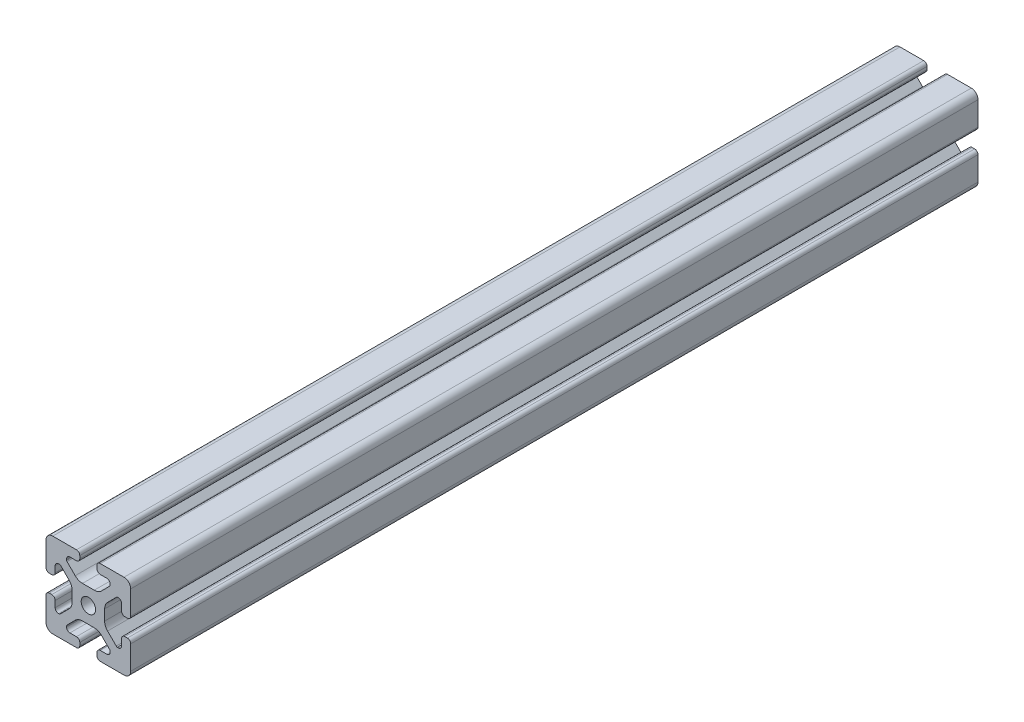
from build123d import *

# Parameters (mm, degrees)
SKETCH1_R           = 3.4
BOSS_EXTRUDE1_DEPTH = 400


with BuildPart() as part:
    # Sketch1 → Boss-Extrude1 (new body)
    with BuildSketch(Plane.XY):
        with BuildLine():
            Line((-8.715, -15.524615034), (-5.63, -15.524615034))
            ThreePointArc((-5.63, -15.524615034), (-4.519842354, -15.984457388), (-4.06, -17.094615034))
            Line((-4.06, -17.094615034), (-4.06, -18.43))
            ThreePointArc((-4.06, -18.43), (-4.519842354, -19.540157646), (-5.63, -20))
            Line((-5.63, -20), (-16.674615034, -20))
            ThreePointArc((-16.674615034, -20), (-18.951578385, -19.194274381), (-20, -17.018368134))
            Line((-20, -17.018368134), (-20, -5.757918808))
            ThreePointArc((-20, -5.757918808), (-19.564709668, -4.603883664), (-18.43, -4.120449326))
            Line((-18.43, -4.120449326), (-17.248545805, -4.120449326))
            ThreePointArc((-17.248545805, -4.120449326), (-16.114784845, -4.604407881), (-15.67999625, -5.757919334))
            Line((-15.67999625, -5.757919334), (-15.67999625, -8.715399492))
            ThreePointArc((-15.67999625, -8.715399492), (-15.220153896, -9.825557139), (-14.10999625, -10.285399492))
            Line((-14.10999625, -10.285399492), (-13.816903094, -10.285399492))
            ThreePointArc((-13.816903094, -10.285399492), (-13.526063686, -10.227547937), (-13.279501941, -10.062800646))
            Line((-13.279501941, -10.062800646), (-9.076242789, -5.859541495))
            ThreePointArc((-9.076242789, -5.859541495), (-8.046572221, -4.318530588), (-7.685, -2.500784284))
            Line((-7.685, -2.500784284), (-7.685, 2.500784284))
            ThreePointArc((-7.685, 2.500784284), (-8.046572221, 4.318530588), (-9.076242789, 5.859541495))
            Line((-9.076242789, 5.859541495), (-13.040489136, 9.823787841))
            ThreePointArc((-13.040489136, 9.823787841), (-13.354224618, 10.012729352), (-13.71989919, 10.033001362))
            Line((-13.71989919, 10.033001362), (-14.05520779, 10.044710596))
            ThreePointArc((-14.05520779, 10.044710596), (-15.200613642, 9.605030484), (-15.68, 8.475666998))
            Line((-15.68, 8.475666998), (-15.68, 5.572979049))
            ThreePointArc((-15.68, 5.572979049), (-16.139842354, 4.462821403), (-17.25, 4.002979049))
            Line((-17.25, 4.002979049), (-18.43, 4.002979049))
            ThreePointArc((-18.43, 4.002979049), (-19.540157646, 4.462821403), (-20, 5.572979049))
            Line((-20, 5.572979049), (-20, 13.004526564))
            Line((-20, 13.004526564), (-20, 16.83))
            ThreePointArc((-20, 16.83), (-19.071528496, 19.071528496), (-16.83, 20))
            Line((-16.83, 20), (-5.63, 20))
            ThreePointArc((-5.63, 20), (-4.519842354, 19.540157646), (-4.06, 18.43))
            Line((-4.06, 18.43), (-4.06, 17.094615034))
            ThreePointArc((-4.06, 17.094615034), (-4.519842354, 15.984457388), (-5.63, 15.524615034))
            Line((-5.63, 15.524615034), (-8.715, 15.524615034))
            ThreePointArc((-8.715, 15.524615034), (-9.825157646, 15.06477268), (-10.285, 13.954615034))
            Line((-10.285, 13.954615034), (-10.285, 13.492503602))
            ThreePointArc((-10.285, 13.492503602), (-10.227148445, 13.201664194), (-10.062401154, 12.955102448))
            Line((-10.062401154, 12.955102448), (-6.217092793, 9.109794088))
            ThreePointArc((-6.217092793, 9.109794088), (-4.63891877, 8.055291919), (-2.777335583, 7.685))
            Line((-2.777335583, 7.685), (2.777335583, 7.685))
            ThreePointArc((2.777335583, 7.685), (4.63891877, 8.055291919), (6.217092793, 9.109794088))
            Line((6.217092793, 9.109794088), (10.062401154, 12.955102448))
            ThreePointArc((10.062401154, 12.955102448), (10.227148445, 13.201664194), (10.285, 13.492503602))
            Line((10.285, 13.492503602), (10.285, 13.954615034))
            ThreePointArc((10.285, 13.954615034), (9.825157646, 15.06477268), (8.715, 15.524615034))
            Line((8.715, 15.524615034), (5.63, 15.524615034))
            ThreePointArc((5.63, 15.524615034), (4.519842354, 15.984457388), (4.06, 17.094615034))
            Line((4.06, 17.094615034), (4.06, 18.43))
            ThreePointArc((4.06, 18.43), (4.519842354, 19.540157646), (5.63, 20))
            Line((5.63, 20), (12.979635074, 20))
            Line((12.979635074, 20), (16.83, 20))
            ThreePointArc((16.83, 20), (19.071528496, 19.071528496), (20, 16.83))
            Line((20, 16.83), (20, 13.001098436))
            Line((20, 13.001098436), (20, 5.630000526))
            ThreePointArc((20, 5.630000526), (19.540157646, 4.519842879), (18.43, 4.060000526))
            Line((18.43, 4.060000526), (17.24999625, 4.060000526))
            ThreePointArc((17.24999625, 4.060000526), (16.139838603, 4.519842879), (15.67999625, 5.630000526))
            Line((15.67999625, 5.630000526), (15.67999625, 8.715399492))
            ThreePointArc((15.67999625, 8.715399492), (15.220153896, 9.825557139), (14.10999625, 10.285399492))
            Line((14.10999625, 10.285399492), (13.816903094, 10.285399492))
            ThreePointArc((13.816903094, 10.285399492), (13.526063686, 10.227547937), (13.279501941, 10.062800646))
            Line((13.279501941, 10.062800646), (9.076242789, 5.859541495))
            ThreePointArc((9.076242789, 5.859541495), (8.046572221, 4.318530588), (7.685, 2.500784284))
            Line((7.685, 2.500784284), (7.685, -2.500784284))
            ThreePointArc((7.685, -2.500784284), (8.046572221, -4.318530588), (9.076242789, -5.859541495))
            Line((9.076242789, -5.859541495), (13.163657296, -9.946956002))
            ThreePointArc((13.163657296, -9.946956002), (13.35903797, -10.160433474), (13.6200547, -10.285399492))
            Line((13.6200547, -10.285399492), (14.10999625, -10.285399492))
            ThreePointArc((14.10999625, -10.285399492), (15.220153896, -9.825557139), (15.67999625, -8.715399492))
            Line((15.67999625, -8.715399492), (15.67999625, -5.630000526))
            ThreePointArc((15.67999625, -5.630000526), (16.139838603, -4.519842879), (17.24999625, -4.060000526))
            Line((17.24999625, -4.060000526), (18.43, -4.060000526))
            ThreePointArc((18.43, -4.060000526), (19.540157646, -4.519842879), (20, -5.630000526))
            Line((20, -5.630000526), (20, -16.83))
            ThreePointArc((20, -16.83), (19.071528496, -19.071528496), (16.83, -20))
            Line((16.83, -20), (13, -20))
            Line((13, -20), (5.63, -20))
            ThreePointArc((5.63, -20), (4.519842354, -19.540157646), (4.06, -18.43))
            Line((4.06, -18.43), (4.06, -17.094615034))
            ThreePointArc((4.06, -17.094615034), (4.519842354, -15.984457388), (5.63, -15.524615034))
            Line((5.63, -15.524615034), (8.715, -15.524615034))
            ThreePointArc((8.715, -15.524615034), (9.825157646, -15.06477268), (10.285, -13.954615034))
            Line((10.285, -13.954615034), (10.285, -13.492503602))
            ThreePointArc((10.285, -13.492503602), (10.227148445, -13.201664194), (10.062401154, -12.955102448))
            Line((10.062401154, -12.955102448), (6.217092793, -9.109794088))
            ThreePointArc((6.217092793, -9.109794088), (4.63891877, -8.055291919), (2.777335583, -7.685))
            Line((2.777335583, -7.685), (-2.777335583, -7.685))
            ThreePointArc((-2.777335583, -7.685), (-4.63891877, -8.055291919), (-6.217092793, -9.109794088))
            Line((-6.217092793, -9.109794088), (-10.062401154, -12.955102448))
            ThreePointArc((-10.062401154, -12.955102448), (-10.227148445, -13.201664194), (-10.285, -13.492503602))
            Line((-10.285, -13.492503602), (-10.285, -13.954615034))
            ThreePointArc((-10.285, -13.954615034), (-9.825157646, -15.06477268), (-8.715, -15.524615034))
        make_face()
        Circle(SKETCH1_R, mode=Mode.SUBTRACT)
    extrude(amount=BOSS_EXTRUDE1_DEPTH)


solid = part.part
